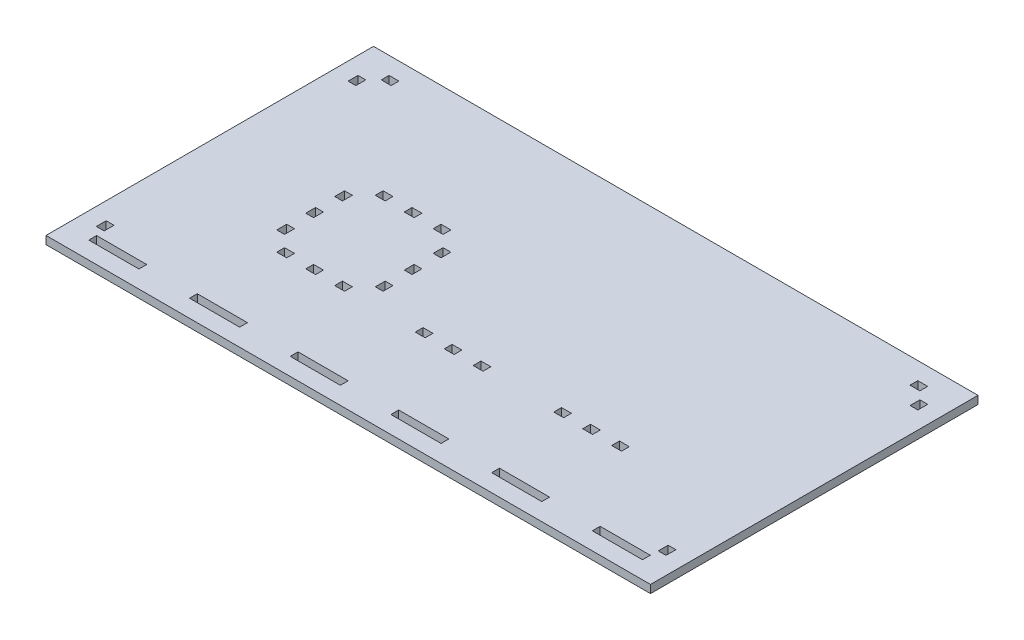
from build123d import *

# Parameters (mm, degrees)
SKETCH1_W           = 240
SKETCH1_H           = 130
SKETCH1_W_2         = 3.175
SKETCH1_H_2         = 4
SKETCH1_W_3         = 20
SKETCH1_H_3         = 3.175
SKETCH1_W_4         = 4
BOSS_EXTRUDE1_DEPTH = 3.175
SKETCH2_W           = 240.08128
SKETCH2_H           = 130.08128
SKETCH2_W_2         = 3.91872
SKETCH2_H_2         = 3.09372
SKETCH2_W_3         = 3.09372
SKETCH2_H_3         = 3.91872
SKETCH2_W_4         = 19.91872
BOSS_EXTRUDE2_DEPTH = 3.175


with BuildPart() as part:
    # Sketch1 → Boss-Extrude1 (new body)
    with BuildSketch(Plane(origin=(0, 0, 0), x_dir=(1, 0, 0), z_dir=(0, 1, 0))):
        Rectangle(SKETCH1_W, SKETCH1_H)
        with Locations((-111.5875, -50)):
            Rectangle(SKETCH1_W_2, SKETCH1_H_2, mode=Mode.SUBTRACT)
        with Locations((-100, -56.5875)):
            Rectangle(SKETCH1_W_3, SKETCH1_H_3, mode=Mode.SUBTRACT)
        with Locations((-60, -56.5875)):
            Rectangle(SKETCH1_W_3, SKETCH1_H_3, mode=Mode.SUBTRACT)
        with Locations((-20, -56.5875)):
            Rectangle(SKETCH1_W_3, SKETCH1_H_3, mode=Mode.SUBTRACT)
        with Locations((-11.5, -23.4125)):
            Rectangle(SKETCH1_W_4, SKETCH1_H_3, mode=Mode.SUBTRACT)
        with Locations((-66.5, -23.4125)):
            Rectangle(SKETCH1_W_4, SKETCH1_H_3, mode=Mode.SUBTRACT)
        with Locations((-55, -23.4125)):
            Rectangle(SKETCH1_W_4, SKETCH1_H_3, mode=Mode.SUBTRACT)
        with Locations((-43.5, -23.4125)):
            Rectangle(SKETCH1_W_4, SKETCH1_H_3, mode=Mode.SUBTRACT)
        with Locations((-35.4375, -15.35)):
            Rectangle(SKETCH1_W_2, SKETCH1_H_2, mode=Mode.SUBTRACT)
        with Locations((-35.4375, -3.85)):
            Rectangle(SKETCH1_W_2, SKETCH1_H_2, mode=Mode.SUBTRACT)
        with Locations((-35.4375, 7.65)):
            Rectangle(SKETCH1_W_2, SKETCH1_H_2, mode=Mode.SUBTRACT)
        with Locations((-43.5, 15.7125)):
            Rectangle(SKETCH1_W_4, SKETCH1_H_3, mode=Mode.SUBTRACT)
        with Locations((-55, 15.7125)):
            Rectangle(SKETCH1_W_4, SKETCH1_H_3, mode=Mode.SUBTRACT)
        with Locations((-66.5, 15.7125)):
            Rectangle(SKETCH1_W_4, SKETCH1_H_3, mode=Mode.SUBTRACT)
        with Locations((-74.5625, 7.65)):
            Rectangle(SKETCH1_W_2, SKETCH1_H_2, mode=Mode.SUBTRACT)
        with Locations((-74.5625, -3.85)):
            Rectangle(SKETCH1_W_2, SKETCH1_H_2, mode=Mode.SUBTRACT)
        with Locations((-74.5625, -15.35)):
            Rectangle(SKETCH1_W_2, SKETCH1_H_2, mode=Mode.SUBTRACT)
        with Locations((20, -56.5875)):
            Rectangle(SKETCH1_W_3, SKETCH1_H_3, mode=Mode.SUBTRACT)
        with Locations((60, -56.5875)):
            Rectangle(SKETCH1_W_3, SKETCH1_H_3, mode=Mode.SUBTRACT)
        with Locations((100, -56.5875)):
            Rectangle(SKETCH1_W_3, SKETCH1_H_3, mode=Mode.SUBTRACT)
        with Locations((111.5875, -50)):
            Rectangle(SKETCH1_W_2, SKETCH1_H_2, mode=Mode.SUBTRACT)
        with Locations((0, -23.4125)):
            Rectangle(SKETCH1_W_4, SKETCH1_H_3, mode=Mode.SUBTRACT)
        with Locations((11.5, -23.4125)):
            Rectangle(SKETCH1_W_4, SKETCH1_H_3, mode=Mode.SUBTRACT)
        with Locations((43.5, -23.4125)):
            Rectangle(SKETCH1_W_4, SKETCH1_H_3, mode=Mode.SUBTRACT)
        with Locations((55, -23.4125)):
            Rectangle(SKETCH1_W_4, SKETCH1_H_3, mode=Mode.SUBTRACT)
        with Locations((66.5, -23.4125)):
            Rectangle(SKETCH1_W_4, SKETCH1_H_3, mode=Mode.SUBTRACT)
        with Locations((-111.5875, 50)):
            Rectangle(SKETCH1_W_2, SKETCH1_H_2, mode=Mode.SUBTRACT)
        with Locations((-105, 56.5875)):
            Rectangle(SKETCH1_W_4, SKETCH1_H_3, mode=Mode.SUBTRACT)
        with Locations((105, 56.5875)):
            Rectangle(SKETCH1_W_4, SKETCH1_H_3, mode=Mode.SUBTRACT)
        with Locations((111.5875, 50)):
            Rectangle(SKETCH1_W_2, SKETCH1_H_2, mode=Mode.SUBTRACT)
    extrude(amount=BOSS_EXTRUDE1_DEPTH)

    # Sketch2 → Boss-Extrude2 (add)
    with BuildSketch(Plane(origin=(0, 3.175, 0), x_dir=(1, 0, 0), z_dir=(0, 1, 0))):
        Rectangle(SKETCH2_W, SKETCH2_H)
        with Locations((-105, 56.5875)):
            Rectangle(SKETCH2_W_2, SKETCH2_H_2, mode=Mode.SUBTRACT)
        with Locations((-74.5625, -3.85)):
            Rectangle(SKETCH2_W_3, SKETCH2_H_3, mode=Mode.SUBTRACT)
        with Locations((-35.4375, 7.65)):
            Rectangle(SKETCH2_W_3, SKETCH2_H_3, mode=Mode.SUBTRACT)
        with Locations((-111.5875, 50)):
            Rectangle(SKETCH2_W_3, SKETCH2_H_3, mode=Mode.SUBTRACT)
        with Locations((-74.5625, -15.35)):
            Rectangle(SKETCH2_W_3, SKETCH2_H_3, mode=Mode.SUBTRACT)
        with Locations((105, 56.5875)):
            Rectangle(SKETCH2_W_2, SKETCH2_H_2, mode=Mode.SUBTRACT)
        with Locations((-11.5, -23.4125)):
            Rectangle(SKETCH2_W_2, SKETCH2_H_2, mode=Mode.SUBTRACT)
        with Locations((111.5875, 50)):
            Rectangle(SKETCH2_W_3, SKETCH2_H_3, mode=Mode.SUBTRACT)
        with Locations((-66.5, 15.7125)):
            Rectangle(SKETCH2_W_2, SKETCH2_H_2, mode=Mode.SUBTRACT)
        with Locations((-35.4375, -3.85)):
            Rectangle(SKETCH2_W_3, SKETCH2_H_3, mode=Mode.SUBTRACT)
        with Locations((-111.5875, -50)):
            Rectangle(SKETCH2_W_3, SKETCH2_H_3, mode=Mode.SUBTRACT)
        with Locations((-55, 15.7125)):
            Rectangle(SKETCH2_W_2, SKETCH2_H_2, mode=Mode.SUBTRACT)
        with Locations((-100, -56.5875)):
            Rectangle(SKETCH2_W_4, SKETCH2_H_2, mode=Mode.SUBTRACT)
        with Locations((-35.4375, -15.35)):
            Rectangle(SKETCH2_W_3, SKETCH2_H_3, mode=Mode.SUBTRACT)
        with Locations((-60, -56.5875)):
            Rectangle(SKETCH2_W_4, SKETCH2_H_2, mode=Mode.SUBTRACT)
        with Locations((-43.5, 15.7125)):
            Rectangle(SKETCH2_W_2, SKETCH2_H_2, mode=Mode.SUBTRACT)
        with Locations((-20, -56.5875)):
            Rectangle(SKETCH2_W_4, SKETCH2_H_2, mode=Mode.SUBTRACT)
        with Locations((0, -23.4125)):
            Rectangle(SKETCH2_W_2, SKETCH2_H_2, mode=Mode.SUBTRACT)
        with Locations((20, -56.5875)):
            Rectangle(SKETCH2_W_4, SKETCH2_H_2, mode=Mode.SUBTRACT)
        with Locations((-66.5, -23.4125)):
            Rectangle(SKETCH2_W_2, SKETCH2_H_2, mode=Mode.SUBTRACT)
        with Locations((60, -56.5875)):
            Rectangle(SKETCH2_W_4, SKETCH2_H_2, mode=Mode.SUBTRACT)
        with Locations((-55, -23.4125)):
            Rectangle(SKETCH2_W_2, SKETCH2_H_2, mode=Mode.SUBTRACT)
        with Locations((100, -56.5875)):
            Rectangle(SKETCH2_W_4, SKETCH2_H_2, mode=Mode.SUBTRACT)
        with Locations((11.5, -23.4125)):
            Rectangle(SKETCH2_W_2, SKETCH2_H_2, mode=Mode.SUBTRACT)
        with Locations((-43.5, -23.4125)):
            Rectangle(SKETCH2_W_2, SKETCH2_H_2, mode=Mode.SUBTRACT)
        with Locations((111.5875, -50)):
            Rectangle(SKETCH2_W_3, SKETCH2_H_3, mode=Mode.SUBTRACT)
        with Locations((-74.5625, 7.65)):
            Rectangle(SKETCH2_W_3, SKETCH2_H_3, mode=Mode.SUBTRACT)
        with Locations((43.5, -23.4125)):
            Rectangle(SKETCH2_W_2, SKETCH2_H_2, mode=Mode.SUBTRACT)
        with Locations((55, -23.4125)):
            Rectangle(SKETCH2_W_2, SKETCH2_H_2, mode=Mode.SUBTRACT)
        with Locations((66.5, -23.4125)):
            Rectangle(SKETCH2_W_2, SKETCH2_H_2, mode=Mode.SUBTRACT)
    extrude(amount=-BOSS_EXTRUDE2_DEPTH)


solid = part.part
